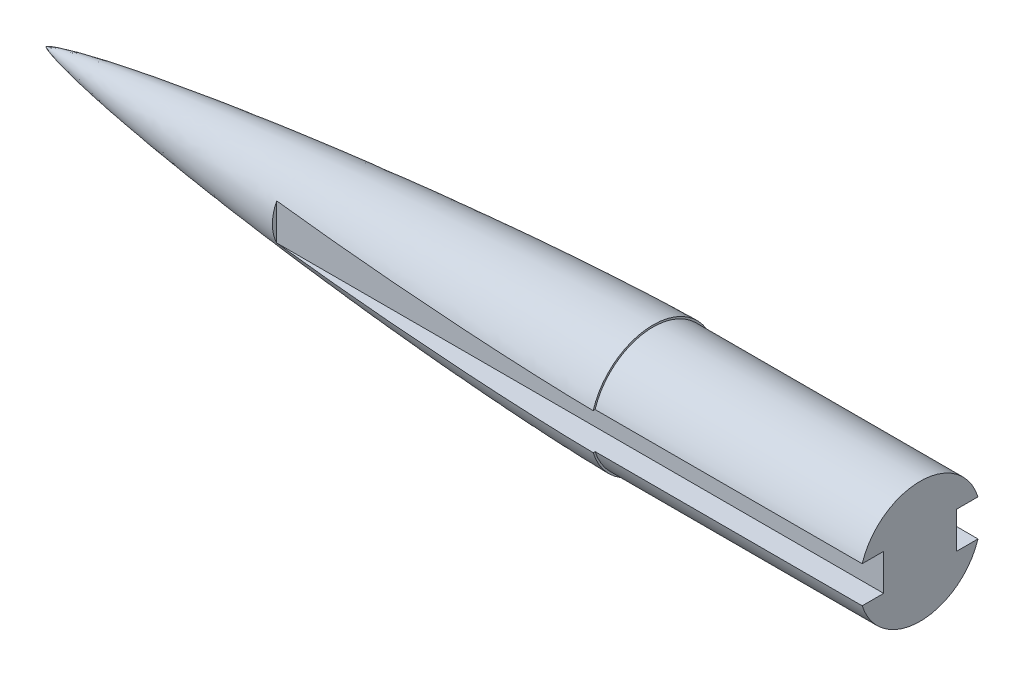
from build123d import *

# Parameters (mm, degrees)
CUT_EXTRUDE1_DEPTH  = 406.4
BOSS_EXTRUDE2_DEPTH = 228.6


with BuildPart() as part:
    # Sketch1 → Revolve1 (revolve)
    with BuildSketch(Plane.XY):
        with BuildLine():
            Line((0, 0), (685.8, 0))
            Line((685.8, 0), (685.8, 63.5))
            Line((685.8, 63.5), (635, 63.5))
            Line((635, 63.5), (635, 65.405))
            add(Edge.make_bspline(
                [(0, 0), (0.002192115, 0.006290208), (0.007522969, 0.018367599), (0.022271668, 0.040384559), (0.056983677, 0.080426255), (0.109817079, 0.130424863), (0.181602896, 0.188889433), (0.283649616, 0.263361483), (0.406270252, 0.344359984), (0.550210431, 0.431764809), (0.715531562, 0.525146598), (0.956716029, 0.653660621), (1.331811412, 0.839140677), (1.970276917, 1.127501619), (3.115826799, 1.592189007), (5.163395415, 2.328403475), (8.933180628, 3.515485788), (16.022028295, 5.446250201), (28.261741777, 8.304992794), (49.178793555, 12.513579304), (77.957328785, 17.487301978), (112.870807325, 22.806136935), (151.857530338, 28.124197322), (190.903568879, 32.982699255), (229.995170685, 37.459233955), (269.123174714, 41.603760556), (308.282068326, 45.445401222), (347.467762428, 49.002567332), (386.677550901, 52.283613526), (425.909385738, 55.28952525), (465.161890457, 58.012752885), (504.434100625, 60.436186371), (538.814064528, 62.266460598), (568.294487813, 63.592457812), (591.989866174, 64.466582586), (607.876612197, 64.942044427), (620.867800744, 65.238425835), (628.943051519, 65.360798765), (632.980968041, 65.399904908), (635, 65.405)],
                knots=[0, 0, 0, 0, 0, 4.1322e-05, 8.2644e-05, 0.000165287, 0.000330575, 0.000495862, 0.00066115, 0.00095525, 0.001249349, 0.001548926, 0.001848503, 0.002664392, 0.003865965, 0.00592961, 0.009578293, 0.016270012, 0.028578882, 0.05187103, 0.088176104, 0.149698422, 0.211220737, 0.272743055, 0.334265373, 0.395787692, 0.457310011, 0.518832329, 0.580354648, 0.641876966, 0.703399285, 0.764921604, 0.826443922, 0.887966241, 0.9187274, 0.94948856, 0.97474428, 0.98737214, 1, 1, 1, 1, 1], degree=4))
        make_face()
    revolve(axis=Axis((0, 0, 0), (1, 0, 0)))

    # Sketch2 → Cut-Extrude1 (cut)
    with BuildSketch(Plane(origin=(685.8, 0, 0), x_dir=(0, 0, -1), z_dir=(1, 0, 0))):
        with BuildLine():
            Line((76.2, 19.05), (62.569253831, 19.05))
            ThreePointArc((62.569253831, 19.05), (64.692179094, 9.629952704), (65.405, 0))
            ThreePointArc((65.405, 0), (64.692179094, -9.629952704), (62.569253831, -19.05))
            Line((62.569253831, -19.05), (76.2, -19.05))
            Line((76.2, -19.05), (76.2, -18.415))
            Line((76.2, -18.415), (76.2, 18.415))
            Line((76.2, 18.415), (76.2, 19.05))
        make_face()
        with BuildLine():
            ThreePointArc((-60.57513929, -19.05), (-63.5, 0), (-60.57513929, 19.05))
            Line((-60.57513929, 19.05), (-62.569253831, 19.05))
            ThreePointArc((-62.569253831, 19.05), (-65.405, 0), (-62.569253831, -19.05))
            Line((-62.569253831, -19.05), (-60.57513929, -19.05))
        make_face()
        with BuildLine():
            Line((62.569253831, 19.05), (60.57513929, 19.05))
            ThreePointArc((60.57513929, 19.05), (62.764525589, 9.636613904), (63.5, 0))
            ThreePointArc((63.5, 0), (62.764525589, -9.636613904), (60.57513929, -19.05))
            Line((60.57513929, -19.05), (62.569253831, -19.05))
            ThreePointArc((62.569253831, -19.05), (64.692179094, -9.629952704), (65.405, 0))
            ThreePointArc((65.405, 0), (64.692179094, 9.629952704), (62.569253831, 19.05))
        make_face()
        with BuildLine():
            ThreePointArc((-62.569253831, -19.05), (-65.405, 0), (-62.569253831, 19.05))
            Line((-62.569253831, 19.05), (-76.2, 19.05))
            Line((-76.2, 19.05), (-76.2, 18.415))
            Line((-76.2, 18.415), (-76.2, -18.415))
            Line((-76.2, -18.415), (-76.2, -19.05))
            Line((-76.2, -19.05), (-62.569253831, -19.05))
        make_face()
        with BuildLine():
            ThreePointArc((-60.57513929, -19.05), (-63.5, 0), (-60.57513929, 19.05))
            Line((-60.57513929, 19.05), (-62.569253831, 19.05))
            ThreePointArc((-62.569253831, 19.05), (-65.405, 0), (-62.569253831, -19.05))
            Line((-62.569253831, -19.05), (-60.57513929, -19.05))
        make_face()
        with BuildLine():
            Line((62.569253831, 19.05), (60.57513929, 19.05))
            ThreePointArc((60.57513929, 19.05), (62.764525589, 9.636613904), (63.5, 0))
            ThreePointArc((63.5, 0), (62.764525589, -9.636613904), (60.57513929, -19.05))
            Line((60.57513929, -19.05), (62.569253831, -19.05))
            ThreePointArc((62.569253831, -19.05), (64.692179094, -9.629952704), (65.405, 0))
            ThreePointArc((65.405, 0), (64.692179094, 9.629952704), (62.569253831, 19.05))
        make_face()
        with BuildLine():
            Line((-38.1, -19.05), (-38.1, 19.05))
            Line((-38.1, 19.05), (-60.57513929, 19.05))
            ThreePointArc((-60.57513929, 19.05), (-63.5, 0), (-60.57513929, -19.05))
            Line((-60.57513929, -19.05), (-38.1, -19.05))
        make_face()
        with BuildLine():
            Line((60.57513929, 19.05), (38.1, 19.05))
            Line((38.1, 19.05), (38.1, -19.05))
            Line((38.1, -19.05), (60.57513929, -19.05))
            ThreePointArc((60.57513929, -19.05), (62.764525589, -9.636613904), (63.5, 0))
            ThreePointArc((63.5, 0), (62.764525589, 9.636613904), (60.57513929, 19.05))
        make_face()
    extrude(amount=-CUT_EXTRUDE1_DEPTH, mode=Mode.SUBTRACT)

    # Sketch5 → Boss-Extrude2 (add)
    with BuildSketch(Plane(origin=(685.8, 0, 0), x_dir=(0, 0, -1), z_dir=(1, 0, 0))):
        with BuildLine():
            Line((-60.57513929, 19.05), (-38.1, 19.05))
            Line((-38.1, 19.05), (-38.1, -19.05))
            Line((-38.1, -19.05), (-60.57513929, -19.05))
            ThreePointArc((-60.57513929, -19.05), (0, -63.5), (60.57513929, -19.05))
            Line((60.57513929, -19.05), (38.1, -19.05))
            Line((38.1, -19.05), (38.1, 19.05))
            Line((38.1, 19.05), (60.57513929, 19.05))
            ThreePointArc((60.57513929, 19.05), (0, 63.5), (-60.57513929, 19.05))
        make_face()
    extrude(amount=BOSS_EXTRUDE2_DEPTH)


solid = part.part
